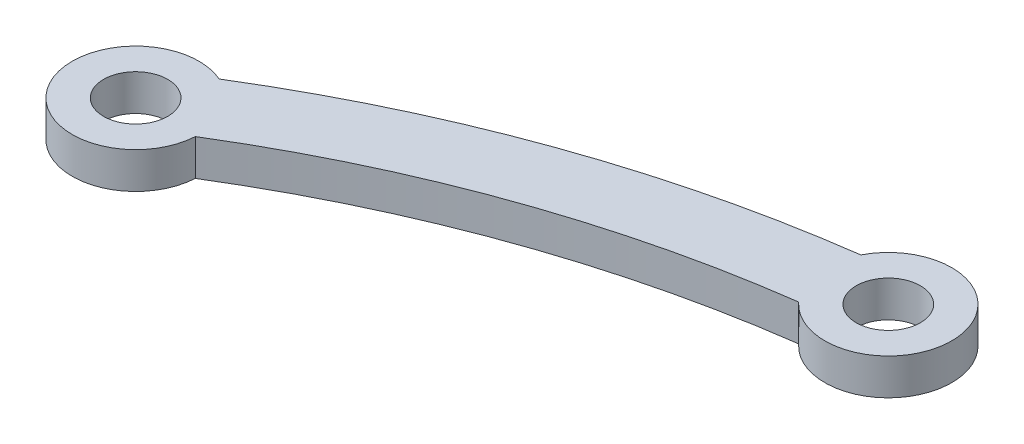
from build123d import *

# Parameters (mm, degrees)
SKETCH1_R           = 2.2479
BOSS_EXTRUDE1_DEPTH = 2.54


with BuildPart() as part:
    # Sketch1 → Boss-Extrude1 (new body)
    with BuildSketch(Plane(origin=(0, 0, 0), x_dir=(1, 0, 0), z_dir=(0, 1, 0))):
        with BuildLine():
            ThreePointArc((-45.432234663, 16.772249877), (-47.057593576, 17.142246239), (-48.704953523, 16.887503017))
            ThreePointArc((-48.704953523, 16.887503017), (-51.401536194, 11.209079653), (-45.72311283, 8.512496983))
            ThreePointArc((-45.72311283, 8.512496983), (-43.657889832, 10.033191137), (-42.77654479, 12.441694335))
            ThreePointArc((-42.77654479, 12.441694335), (-27.77054446, 19.617887904), (-11.605859319, 23.539718385))
            ThreePointArc((-11.605859319, 23.539718385), (-9.400722485, 22.2301275), (-6.839156241, 22.356757346))
            ThreePointArc((-6.839156241, 22.356757346), (-4.142573571, 28.03518071), (-9.820996935, 30.731763381))
            ThreePointArc((-9.820996935, 30.731763381), (-11.258679861, 29.888106632), (-12.28449584, 28.574184838))
            ThreePointArc((-12.28449584, 28.574184838), (-29.474453428, 24.403605638), (-45.432234663, 16.772249877))
        make_face()
        with Locations((-47.214033176, 12.7)):
            Circle(SKETCH1_R, mode=Mode.SUBTRACT)
        with Locations((-8.330076588, 26.544260363)):
            Circle(SKETCH1_R, mode=Mode.SUBTRACT)
    extrude(amount=BOSS_EXTRUDE1_DEPTH)


solid = part.part
